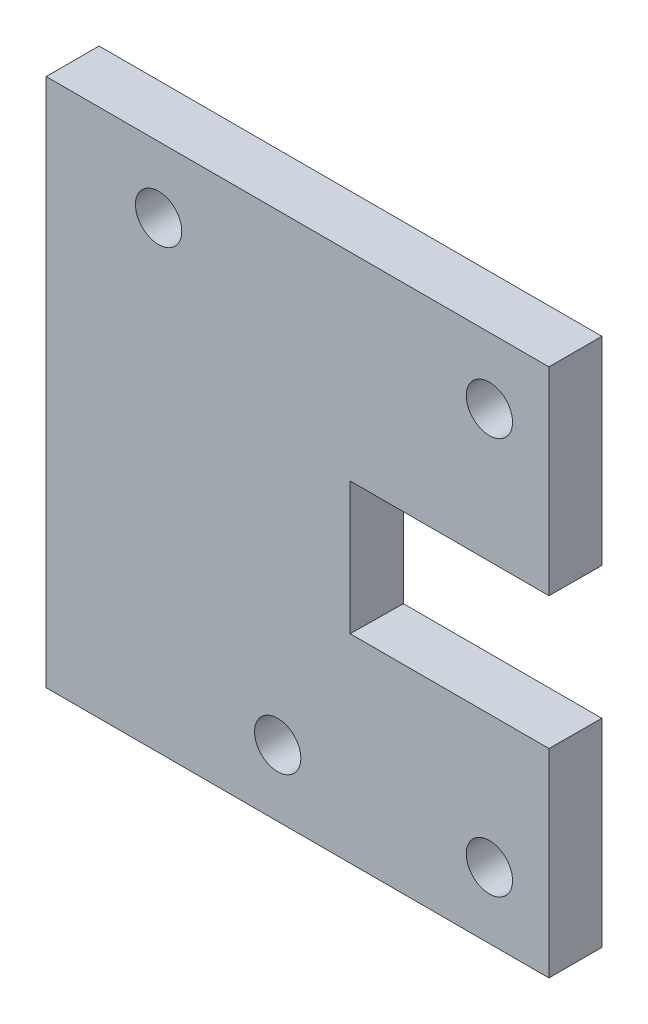
from build123d import *

# Parameters (mm, degrees)
SKETCH_1_W          = 50
SKETCH_1_H          = 40
EXTRUDE_1_DEPTH     = 4
SKETCH_2_R          = 1.75
CUT_EXTRUDE_1_DEPTH = 4
SKETCH_3_W          = 4
SKETCH_3_H          = 40
CUT_EXTRUDE_2_DEPTH = 12
SKETCH_8_W          = 16
SKETCH_8_H          = 10
SKETCH_11_W         = 16
SKETCH_11_H         = 10


with BuildPart() as part:
    # 草图1 → 凸台-拉伸1 (new body)
    with BuildSketch(Plane.XY):
        Rectangle(SKETCH_1_W, SKETCH_1_H)
    extrude(amount=EXTRUDE_1_DEPTH)

    # 草图2 → 切除-拉伸1 (cut)
    with BuildSketch(Plane.XY.offset(4)):
        with Locations((-20.5, 15)):
            Circle(SKETCH_2_R)
        with Locations((-4.5, 15)):
            Circle(SKETCH_2_R)
        with Locations((20.5, 15)):
            Circle(SKETCH_2_R)
        with Locations((20.5, -15)):
            Circle(SKETCH_2_R)
        with Locations((4.5, -15)):
            Circle(SKETCH_2_R)
        with Locations((-20.5, -15)):
            Circle(SKETCH_2_R)
    extrude(amount=-CUT_EXTRUDE_1_DEPTH, mode=Mode.SUBTRACT)

    # 草图3 → 切除-拉伸2 (cut)
    with BuildSketch(Plane.ZY.offset(25)):
        with Locations((2, 0)):
            Rectangle(SKETCH_3_W, SKETCH_3_H)
    extrude(amount=-CUT_EXTRUDE_2_DEPTH, mode=Mode.SUBTRACT)

    # 草图8 → 切除-放样5 section 0
    with BuildSketch(Plane.XY):
        with Locations((18, 0)):
            Rectangle(SKETCH_8_W, SKETCH_8_H)
    # 草图11 → 切除-放样5 section 1
    with BuildSketch(Plane.XY.offset(4)):
        with Locations((17.972560725, 0.020424216)):
            Rectangle(SKETCH_11_W, SKETCH_11_H)
    loft(mode=Mode.SUBTRACT)


solid = part.part
